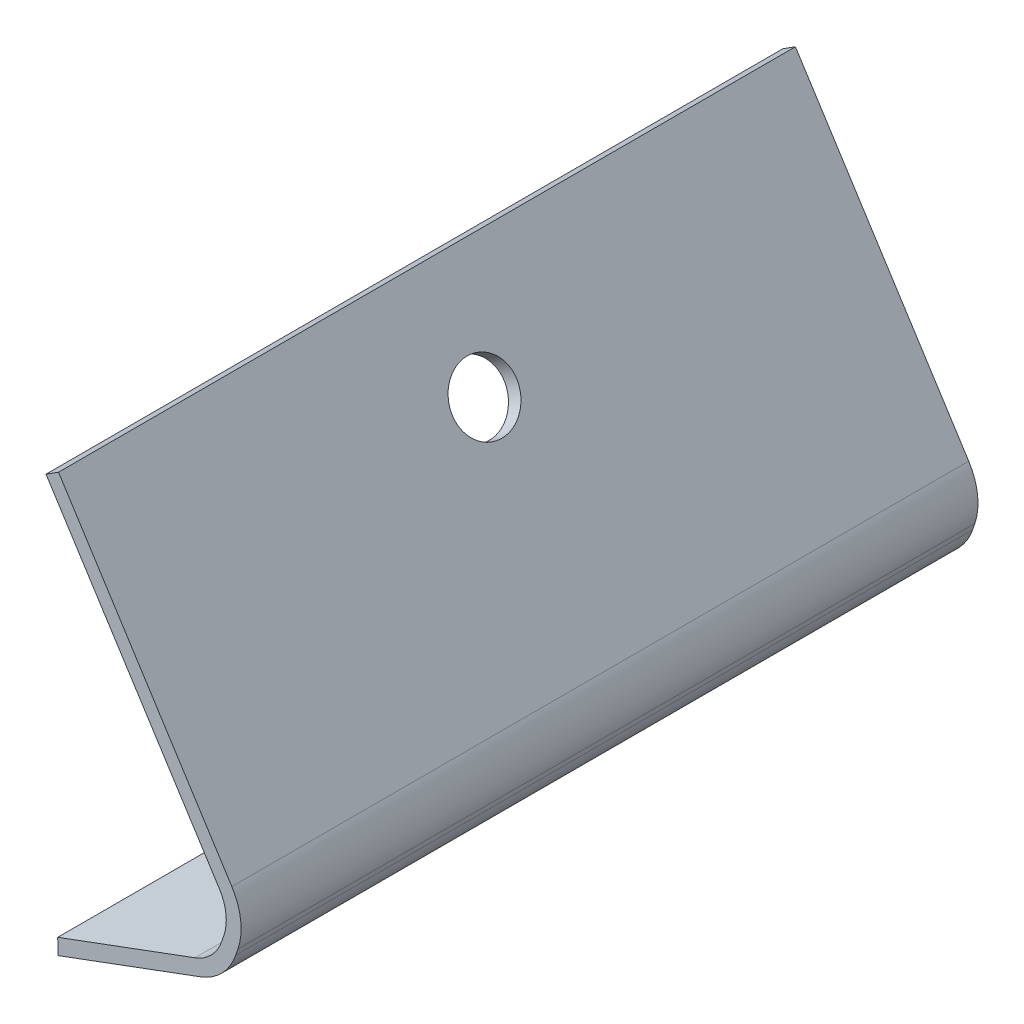
from build123d import *

# Parameters (mm, degrees)
BOSS_EXTRUDE1_START = -1.5748
BOSS_EXTRUDE1_DEPTH = 126.1872
SKETCH2_R           = 5.499987026
CUT_EXTRUDE1_DEPTH  = 63.5


with BuildPart() as part:
    # Sketch1 → Boss-Extrude1 (new body)
    with BuildSketch(Plane.XY.offset(BOSS_EXTRUDE1_START)):
        with BuildLine():
            Line((5.5372, 43.3324), (35.215013396, -3.286034747))
            ThreePointArc((35.215013396, -3.286034747), (36.732607503, -7.536738968), (36.259288034, -12.025340858))
            Line((36.259288034, -12.025340858), (35.882961927, -13.127438743))
            ThreePointArc((35.882961927, -13.127438743), (33.545277751, -16.934256169), (29.80068515, -19.370370386))
            Line((29.80068515, -19.370370386), (5.435919899, -28.405771229))
            Line((5.435919899, -28.405771229), (5.401855854, -25.709375395))
            Line((5.401855854, -25.709375395), (28.91752571, -16.988852088))
            ThreePointArc((28.91752571, -16.988852088), (31.725970161, -15.161766425), (33.479233293, -12.306653356))
            Line((33.479233293, -12.306653356), (33.8555594, -11.204555471))
            ThreePointArc((33.8555594, -11.204555471), (34.210549002, -7.838104053), (33.072353421, -4.650075887))
            Line((33.072353421, -4.650075887), (3.394540025, 41.96835886))
            Line((3.394540025, 41.96835886), (5.5372, 43.3324))
        make_face()
    extrude(amount=-BOSS_EXTRUDE1_DEPTH)

    # Sketch2 → Cut-Extrude1 (cut)
    with BuildSketch(Plane(origin=(23.570559322, 15.005279885, 0), x_dir=(0, 0, -1), z_dir=(0.843566919, 0.537024071, 0))):
        with Locations((64.6684, 15.22665607)):
            Circle(SKETCH2_R)
    extrude(amount=-CUT_EXTRUDE1_DEPTH, mode=Mode.SUBTRACT)


solid = part.part
